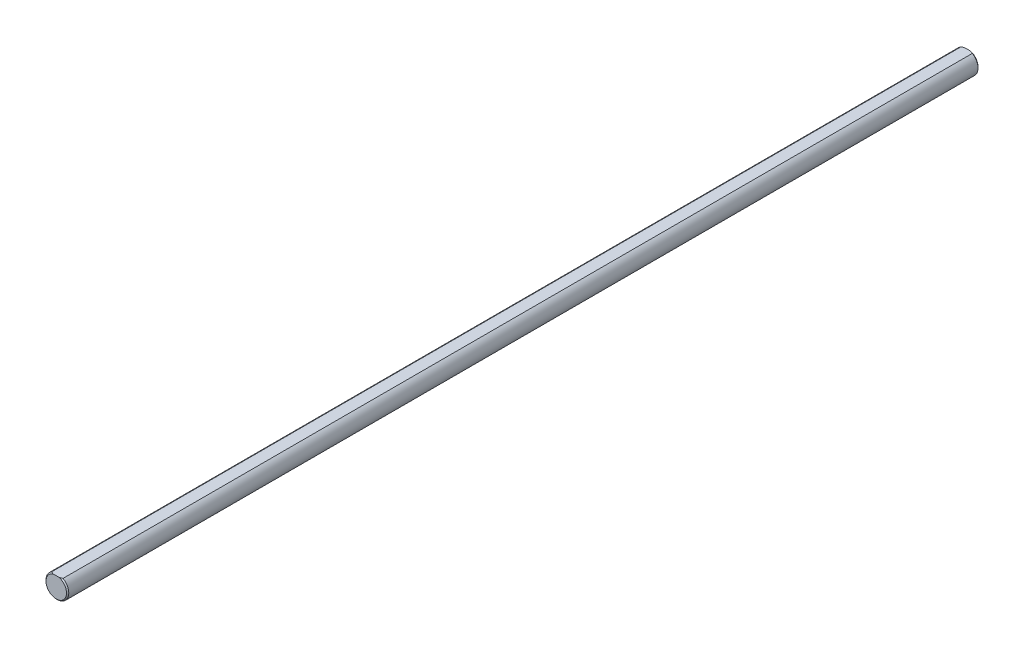
from build123d import *

# Parameters (mm, degrees)
SKETCH3_R                = 5
BOSS_EXTRUDE2_DEPTH      = 200
BOSS_EXTRUDE2_DEPTH_BACK = 200
CUT_EXTRUDE5_DEPTH       = 201
CUT_EXTRUDE5_DEPTH_BACK  = 201
CHAMFER1_SIZE            = 0.5


with BuildPart() as part:
    # Sketch3 → Boss-Extrude2 (new body, two sides)
    with BuildSketch(Plane.XY) as boss_extrude2_sk:
        Circle(SKETCH3_R)
    extrude(amount=BOSS_EXTRUDE2_DEPTH)
    extrude(boss_extrude2_sk.sketch, amount=-BOSS_EXTRUDE2_DEPTH_BACK)

    # Sketch10 → Cut-Extrude5 (cut, two sides)
    with BuildSketch(Plane.XY) as cut_extrude5_sk:
        with BuildLine():
            Line((-2.5, 4.330127019), (2.5, 4.330127019))
            ThreePointArc((2.5, 4.330127019), (0, 5), (-2.5, 4.330127019))
        make_face()
    extrude(amount=CUT_EXTRUDE5_DEPTH, mode=Mode.SUBTRACT)
    extrude(cut_extrude5_sk.sketch, amount=-CUT_EXTRUDE5_DEPTH_BACK, mode=Mode.SUBTRACT)

    # Chamfer1
    chamfer1_edges = [part.edges().sort_by_distance(p)[0] for p in [
        (0, -5, -200),
        (0, -5, 200),
    ]]
    chamfer(chamfer1_edges, length=CHAMFER1_SIZE)


solid = part.part
